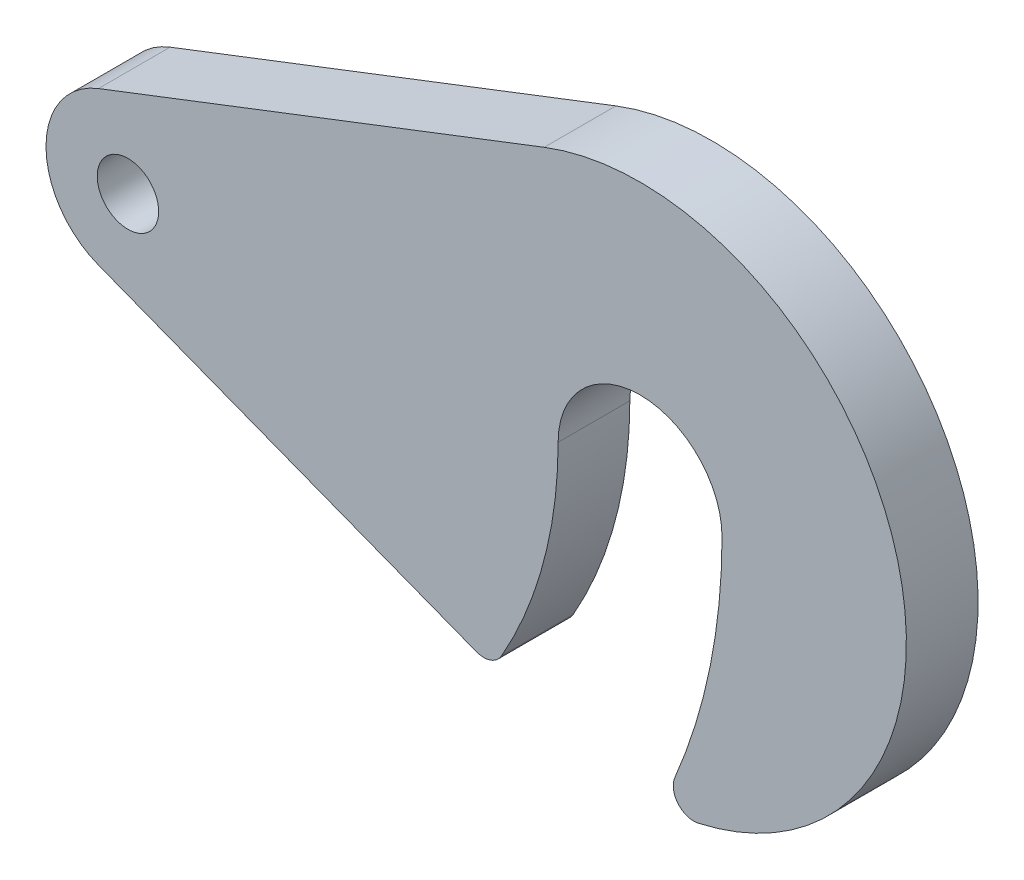
from build123d import *

# Parameters (mm, degrees)
SKICA1_R                = 3
P_IDAT_VYSUNUT_M2_DEPTH = 7


with BuildPart() as part:
    # Skica1 → Přidat vysunutím2 (new body)
    with BuildSketch(Plane.XY):
        with BuildLine():
            Line((40.64, 24.256759883), (-2.88, 7.463618425))
            ThreePointArc((-2.88, 7.463618425), (-8, 0), (-2.88, -7.463618425))
            Line((-2.88, -7.463618425), (34.015875108, -21.700696777))
            ThreePointArc((34.015875108, -21.700696777), (35.406329056, -21.719066966), (36.472668864, -20.82653178))
            ThreePointArc((36.472668864, -20.82653178), (40.594655389, -10.773762289), (42, 0))
            ThreePointArc((42, 0), (50, 8), (58, 0))
            ThreePointArc((58, 0), (56.838027177, -11.55156555), (53.398666667, -22.640282644))
            ThreePointArc((53.398666667, -22.640282644), (53.703822927, -24.701669361), (55.676666667, -25.37273055))
            ThreePointArc((55.676666667, -25.37273055), (74.88299251, 7.539010793), (40.64, 24.256759883))
        make_face()
        Circle(SKICA1_R, mode=Mode.SUBTRACT)
    extrude(amount=P_IDAT_VYSUNUT_M2_DEPTH)


solid = part.part
